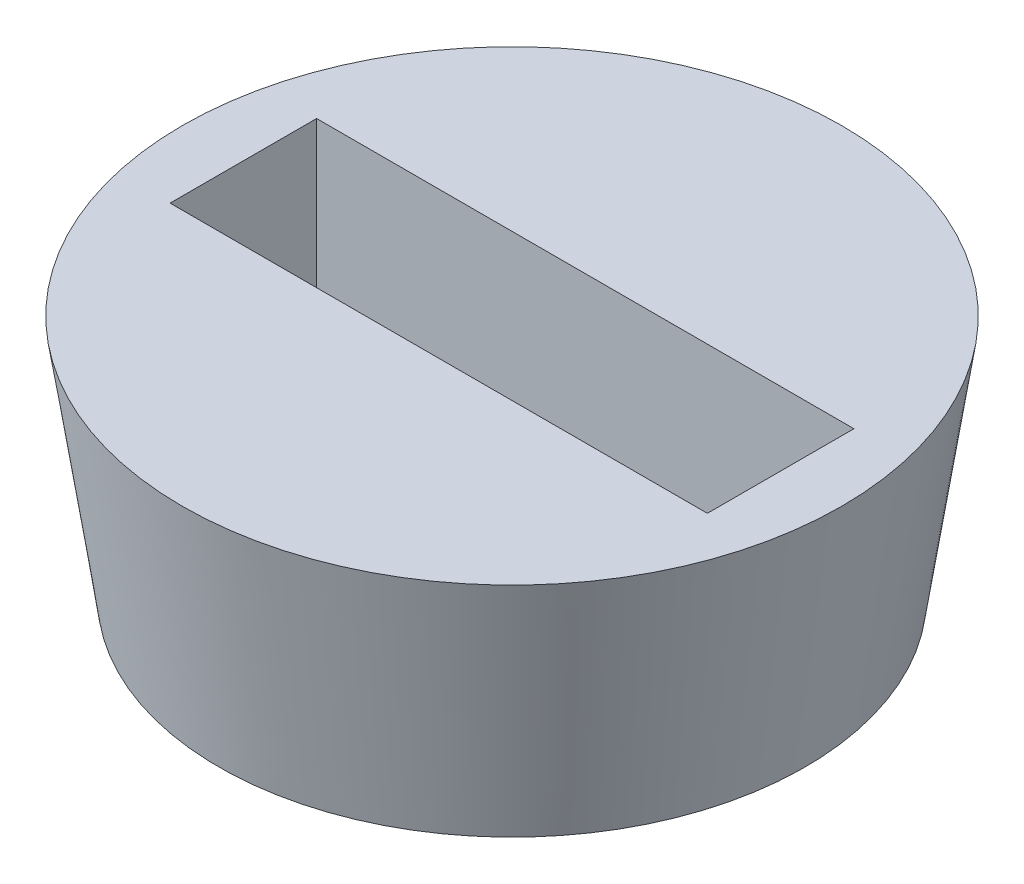
from build123d import *

# Parameters (mm, degrees)
SKETCH2_W          = 11
SKETCH2_H          = 3
CUT_EXTRUDE1_DEPTH = 6


with BuildPart() as part:
    # Sketch1 → Revolve1 (revolve)
    with BuildSketch(Plane.XY):
        Polygon((0, 0), (0, 5), (6.75, 5), (6, 0), align=None)
    revolve(axis=Axis((0, 0, 0), (0, 1, 0)))

    # Sketch2 → Cut-Extrude1 (cut, through all)
    with BuildSketch(Plane(origin=(0, 5, 0), x_dir=(1, 0, 0), z_dir=(0, 1, 0))):
        Rectangle(SKETCH2_W, SKETCH2_H)
    extrude(amount=-CUT_EXTRUDE1_DEPTH, mode=Mode.SUBTRACT)


solid = part.part
